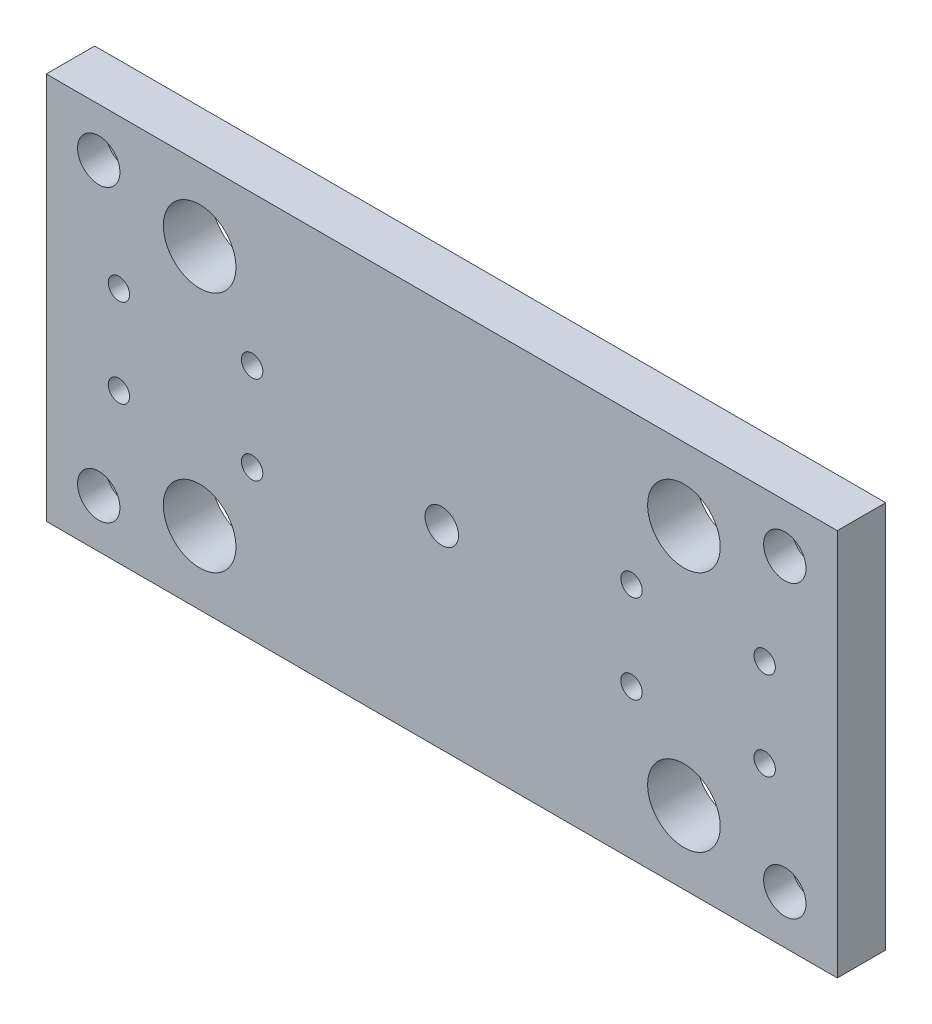
from build123d import *

# Parameters (mm, degrees)
SKETCH1_W                              = 196
SKETCH1_H                              = 96
EXTRUDE1_DEPTH                         = 12
CBORE_FOR_10_MM_CORE_PINS1_D           = 10.5
CBORE_FOR_10_MM_CORE_PINS1_CBORE_D     = 16
CBORE_FOR_10_MM_CORE_PINS1_CBORE_DEPTH = 5
CBORE_FOR_5_MM_CORE_PINS1_D            = 5.3
CBORE_FOR_5_MM_CORE_PINS1_CBORE_D      = 11
CBORE_FOR_5_MM_CORE_PINS1_CBORE_DEPTH  = 3
CBORE_FOR_8_MM_CORE_PINS1_D            = 8.3
CBORE_FOR_8_MM_CORE_PINS1_CBORE_D      = 15
CBORE_FOR_8_MM_CORE_PINS1_CBORE_DEPTH  = 5
F_20_0_20_DIAMETER_HOLE1_D             = 18
F_20_0_20_DIAMETER_HOLE1_DEPTH         = 12
F_20_0_20_DIAMETER_HOLE1_TIP           = 5.407745571


with BuildPart() as part:
    # Sketch1 → Extrude1 (new body)
    with BuildSketch(Plane.XY):
        Rectangle(SKETCH1_W, SKETCH1_H)
    extrude(amount=-EXTRUDE1_DEPTH)

    # CBORE for 10 mm Core Pins1 (through all)
    with Locations(Plane(origin=(0, 0, -12), x_dir=(-1, 0, 0), z_dir=(0, 0, -1))):
        with Locations((-85, 36), (85, 36), (85, -36), (-85, -36)):
            CounterBoreHole(CBORE_FOR_10_MM_CORE_PINS1_D / 2, CBORE_FOR_10_MM_CORE_PINS1_CBORE_D / 2, CBORE_FOR_10_MM_CORE_PINS1_CBORE_DEPTH)

    # CBORE for 5 mm Core Pins1 (through all)
    with Locations(Plane(origin=(0, 0, -12), x_dir=(-1, 0, 0), z_dir=(0, 0, -1))):
        with Locations((47, 10.939957651), (80, 10.939957651), (80, -10.939957651), (47, -10.939957651), (-47, 10.939957651), (-47, -10.939957651), (-80, 10.939957651), (-80, -10.939957651)):
            CounterBoreHole(CBORE_FOR_5_MM_CORE_PINS1_D / 2, CBORE_FOR_5_MM_CORE_PINS1_CBORE_D / 2, CBORE_FOR_5_MM_CORE_PINS1_CBORE_DEPTH)

    # CBORE for 8 mm Core Pins1 (through all)
    with Locations(Plane(origin=(0, 0, -12), x_dir=(-1, 0, 0), z_dir=(0, 0, -1))):
        with Locations((0, 0)):
            CounterBoreHole(CBORE_FOR_8_MM_CORE_PINS1_D / 2, CBORE_FOR_8_MM_CORE_PINS1_CBORE_D / 2, CBORE_FOR_8_MM_CORE_PINS1_CBORE_DEPTH)

    # Ø20.0 (20) Diameter Hole1
    with Locations(Plane(origin=(0, 0, -12), x_dir=(-1, 0, 0), z_dir=(0, 0, -1))):
        with Locations((-60, 30), (60, 30), (60, -30), (-60, -30)):
            Hole(F_20_0_20_DIAMETER_HOLE1_D / 2, depth=F_20_0_20_DIAMETER_HOLE1_DEPTH)
            with Locations((0, 0, -(F_20_0_20_DIAMETER_HOLE1_DEPTH + F_20_0_20_DIAMETER_HOLE1_TIP / 2))):  # 118° drill point
                Cone(0, F_20_0_20_DIAMETER_HOLE1_D / 2, F_20_0_20_DIAMETER_HOLE1_TIP, mode=Mode.SUBTRACT)


solid = part.part
